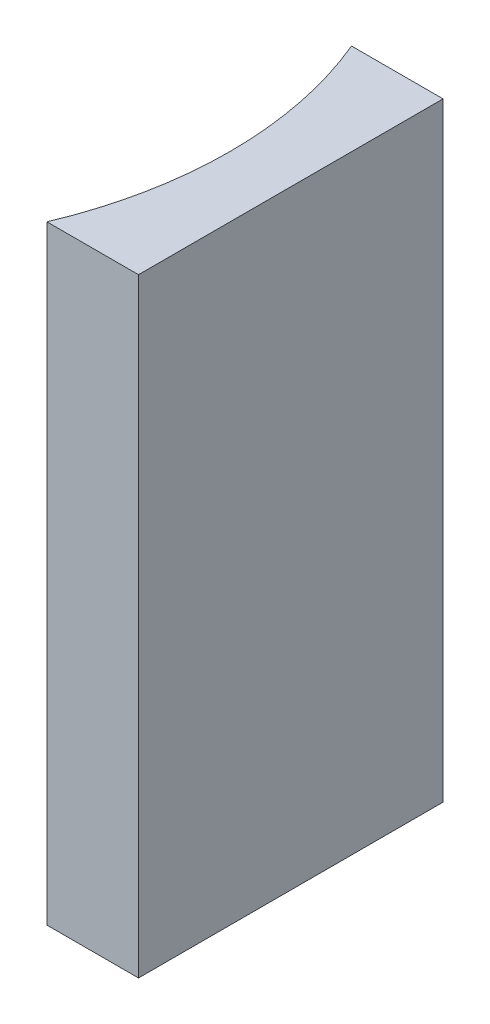
from build123d import *

# Parameters (mm, degrees)
EXTRUDE_1_DEPTH = 20


with BuildPart() as part:
    # 草图1 → 凸台-拉伸1 (new body)
    with BuildSketch(Plane(origin=(0, 0, 0), x_dir=(1, 0, 0), z_dir=(0, 1, 0))):
        with BuildLine():
            Line((0, 0), (0, -10))
            Line((0, -10), (-3.005869004, -10))
            ThreePointArc((-3.005869004, -10), (-2, -5), (-3.005869004, 0))
            Line((-3.005869004, 0), (0, 0))
        make_face()
    extrude(amount=EXTRUDE_1_DEPTH)


solid = part.part
